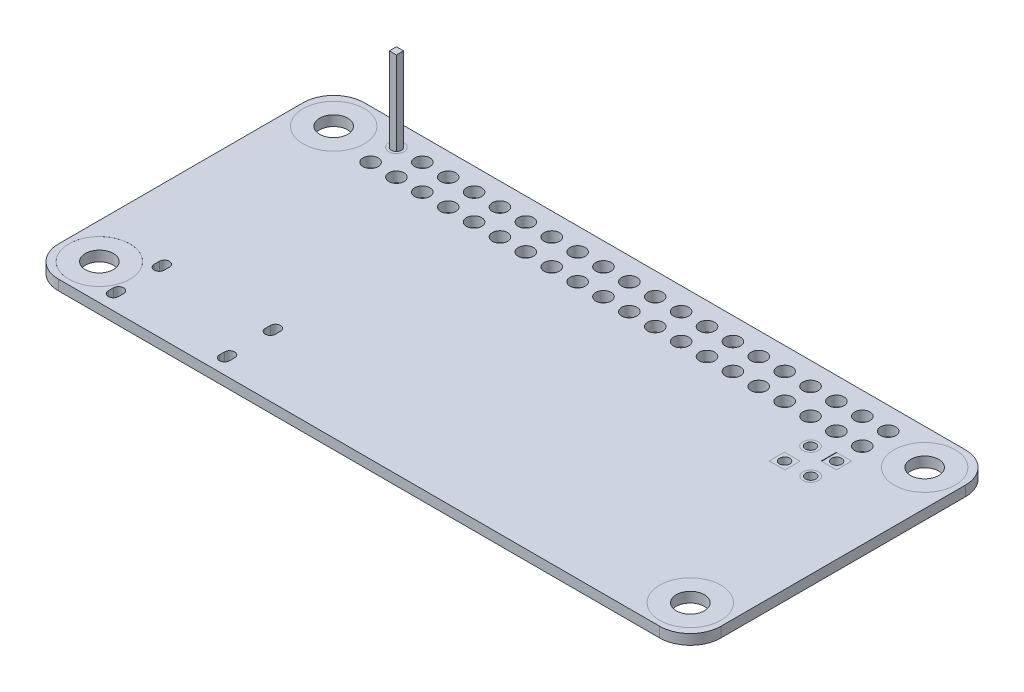
from build123d import *

# Parameters (mm, degrees)
SKETCH1_R                = 3
SKETCH1_R_2              = 0.75
SKETCH1_W                = 1.5
SKETCH1_H                = 1.5
BOSS_EXTRUDE1_DEPTH      = 1
SKETCH2_R                = 0.75
SKETCH2_R_2              = 0.5
BOSS_EXTRUDE2_DEPTH      = 1
SKETCH6_W                = 0.7
SKETCH6_H                = 0.7
BOSS_EXTRUDE5_DEPTH      = 8.2
BOSS_EXTRUDE5_DEPTH_BACK = 3
SKETCH3_R                = 0.75
SKETCH3_R_2              = 0.5
BOSS_EXTRUDE3_DEPTH      = 1
BOSS_EXTRUDE3_2_DEPTH    = 1
SKETCH3_W                = 1.541222488
SKETCH3_H                = 1.5
BOSS_EXTRUDE3_3_DEPTH    = 1
SKETCH3_W_2              = 1.458777511
BOSS_EXTRUDE3_4_DEPTH    = 1
SKETCH4_R                = 3
SKETCH4_R_2              = 1.375
BOSS_EXTRUDE4_DEPTH      = 1
CUT_EXTRUDE1_DEPTH       = 1


with BuildPart() as part:
    # Sketch1 → Boss-Extrude1 (new body)
    with BuildSketch(Plane(origin=(0, 0, 0), x_dir=(1, 0, 0), z_dir=(0, 1, 0))):
        with BuildLine():
            Line((-29.5, -15), (29.5, -15))
            ThreePointArc((29.5, -15), (31.621320344, -14.121320344), (32.5, -12))
            Line((32.5, -12), (32.5, 12))
            ThreePointArc((32.5, 12), (31.621320344, 14.121320344), (29.5, 15))
            Line((29.5, 15), (-29.5, 15))
            ThreePointArc((-29.5, 15), (-31.621320344, 14.121320344), (-32.5, 12))
            Line((-32.5, 12), (-32.5, -12))
            ThreePointArc((-32.5, -12), (-31.621320344, -14.121320344), (-29.5, -15))
        make_face()
        with Locations((-29, 11.5)):
            Circle(SKETCH1_R, mode=Mode.SUBTRACT)
        with Locations((-29, -11.5)):
            Circle(SKETCH1_R, mode=Mode.SUBTRACT)
        with Locations((29, -11.5)):
            Circle(SKETCH1_R, mode=Mode.SUBTRACT)
        with Locations((-24.13, 12.787653136)):
            Circle(SKETCH1_R_2, mode=Mode.SUBTRACT)
        with Locations((-21.59, 12.787653136)):
            Circle(SKETCH1_R_2, mode=Mode.SUBTRACT)
        with Locations((-19.05, 12.787653136)):
            Circle(SKETCH1_R_2, mode=Mode.SUBTRACT)
        with Locations((-16.51, 12.787653136)):
            Circle(SKETCH1_R_2, mode=Mode.SUBTRACT)
        with Locations((-13.97, 12.787653136)):
            Circle(SKETCH1_R_2, mode=Mode.SUBTRACT)
        with Locations((-11.43, 12.787653136)):
            Circle(SKETCH1_R_2, mode=Mode.SUBTRACT)
        with Locations((-8.89, 12.787653136)):
            Circle(SKETCH1_R_2, mode=Mode.SUBTRACT)
        with Locations((-6.35, 12.787653136)):
            Circle(SKETCH1_R_2, mode=Mode.SUBTRACT)
        with Locations((-3.81, 12.787653136)):
            Circle(SKETCH1_R_2, mode=Mode.SUBTRACT)
        with Locations((-1.27, 12.787653136)):
            Circle(SKETCH1_R_2, mode=Mode.SUBTRACT)
        with Locations((1.27, 12.787653136)):
            Circle(SKETCH1_R_2, mode=Mode.SUBTRACT)
        with Locations((3.81, 12.787653136)):
            Circle(SKETCH1_R_2, mode=Mode.SUBTRACT)
        with Locations((6.35, 12.787653136)):
            Circle(SKETCH1_R_2, mode=Mode.SUBTRACT)
        with Locations((8.89, 12.787653136)):
            Circle(SKETCH1_R_2, mode=Mode.SUBTRACT)
        with Locations((11.43, 12.787653136)):
            Circle(SKETCH1_R_2, mode=Mode.SUBTRACT)
        with Locations((13.97, 12.787653136)):
            Circle(SKETCH1_R_2, mode=Mode.SUBTRACT)
        with Locations((16.51, 12.787653136)):
            Circle(SKETCH1_R_2, mode=Mode.SUBTRACT)
        with Locations((19.05, 12.787653136)):
            Circle(SKETCH1_R_2, mode=Mode.SUBTRACT)
        with Locations((21.59, 12.787653136)):
            Circle(SKETCH1_R_2, mode=Mode.SUBTRACT)
        with Locations((24.13, 12.787653136)):
            Circle(SKETCH1_R_2, mode=Mode.SUBTRACT)
        with Locations((-21.59, 10.247653136)):
            Circle(SKETCH1_R_2, mode=Mode.SUBTRACT)
        with Locations((-19.05, 10.247653136)):
            Circle(SKETCH1_R_2, mode=Mode.SUBTRACT)
        with Locations((-16.51, 10.247653136)):
            Circle(SKETCH1_R_2, mode=Mode.SUBTRACT)
        with Locations((-13.97, 10.247653136)):
            Circle(SKETCH1_R_2, mode=Mode.SUBTRACT)
        with Locations((-11.43, 10.247653136)):
            Circle(SKETCH1_R_2, mode=Mode.SUBTRACT)
        with Locations((-8.89, 10.247653136)):
            Circle(SKETCH1_R_2, mode=Mode.SUBTRACT)
        with Locations((-6.35, 10.247653136)):
            Circle(SKETCH1_R_2, mode=Mode.SUBTRACT)
        with Locations((-3.81, 10.247653136)):
            Circle(SKETCH1_R_2, mode=Mode.SUBTRACT)
        with Locations((-1.27, 10.247653136)):
            Circle(SKETCH1_R_2, mode=Mode.SUBTRACT)
        with Locations((1.27, 10.247653136)):
            Circle(SKETCH1_R_2, mode=Mode.SUBTRACT)
        with Locations((3.81, 10.247653136)):
            Circle(SKETCH1_R_2, mode=Mode.SUBTRACT)
        with Locations((6.35, 10.247653136)):
            Circle(SKETCH1_R_2, mode=Mode.SUBTRACT)
        with Locations((8.89, 10.247653136)):
            Circle(SKETCH1_R_2, mode=Mode.SUBTRACT)
        with Locations((11.43, 10.247653136)):
            Circle(SKETCH1_R_2, mode=Mode.SUBTRACT)
        with Locations((13.97, 10.247653136)):
            Circle(SKETCH1_R_2, mode=Mode.SUBTRACT)
        with Locations((16.51, 10.247653136)):
            Circle(SKETCH1_R_2, mode=Mode.SUBTRACT)
        with Locations((19.05, 10.247653136)):
            Circle(SKETCH1_R_2, mode=Mode.SUBTRACT)
        with Locations((21.59, 10.247653136)):
            Circle(SKETCH1_R_2, mode=Mode.SUBTRACT)
        with Locations((24.13, 10.247653136)):
            Circle(SKETCH1_R_2, mode=Mode.SUBTRACT)
        with Locations((-24.13, 10.247653136)):
            Circle(SKETCH1_R_2, mode=Mode.SUBTRACT)
        with Locations((21.59002512, 7.707653136)):
            Circle(SKETCH1_R_2, mode=Mode.SUBTRACT)
        with Locations((24.150636364, 5.167736764)):
            Circle(SKETCH1_R_2, mode=Mode.SUBTRACT)
        with Locations((29, 11.5)):
            Circle(SKETCH1_R, mode=Mode.SUBTRACT)
        with Locations((24.13002512, 7.707653136)):
            Rectangle(SKETCH1_W, SKETCH1_H, mode=Mode.SUBTRACT)
        with Locations((21.610636364, 5.167736764)):
            Rectangle(SKETCH1_W, SKETCH1_H, mode=Mode.SUBTRACT)
    extrude(amount=BOSS_EXTRUDE1_DEPTH)

    # Sketch5 → Cut-Extrude1 (cut)
    with BuildSketch(Plane.XZ):
        with BuildLine():
            Line((-26.078842351, 13.039495396), (-26.078842351, 13.539495396))
            ThreePointArc((-26.078842351, 13.539495396), (-25.578842351, 14.039495396), (-25.078842351, 13.539495396))
            Line((-25.078842351, 13.539495396), (-25.078842351, 13.039495396))
            ThreePointArc((-25.078842351, 13.039495396), (-25.578842351, 12.539495396), (-26.078842351, 13.039495396))
        make_face()
        with BuildLine():
            Line((-15.178842351, 13.039495396), (-15.178842351, 13.539495396))
            ThreePointArc((-15.178842351, 13.539495396), (-14.678842351, 14.039495396), (-14.178842351, 13.539495396))
            Line((-14.178842351, 13.539495396), (-14.178842351, 13.039495396))
            ThreePointArc((-14.178842351, 13.039495396), (-14.678842351, 12.539495396), (-15.178842351, 13.039495396))
        make_face()
        with BuildLine():
            Line((-15.178842351, 8.539495396), (-15.178842351, 9.039495396))
            ThreePointArc((-15.178842351, 9.039495396), (-14.678842351, 9.539495396), (-14.178842351, 9.039495396))
            Line((-14.178842351, 9.039495396), (-14.178842351, 8.539495396))
            ThreePointArc((-14.178842351, 8.539495396), (-14.678842351, 8.039495396), (-15.178842351, 8.539495396))
        make_face()
        with BuildLine():
            Line((-26.078842351, 8.539495396), (-26.078842351, 9.039495396))
            ThreePointArc((-26.078842351, 9.039495396), (-25.578842351, 9.539495396), (-25.078842351, 9.039495396))
            Line((-25.078842351, 9.039495396), (-25.078842351, 8.539495396))
            ThreePointArc((-25.078842351, 8.539495396), (-25.578842351, 8.039495396), (-26.078842351, 8.539495396))
        make_face()
    extrude(amount=-CUT_EXTRUDE1_DEPTH, mode=Mode.SUBTRACT)


with BuildPart() as body_2:
    # Sketch2 → Boss-Extrude2 (new body)
    with BuildSketch(Plane(origin=(0, 0, 0), x_dir=(1, 0, 0), z_dir=(0, 1, 0))):
        with Locations((-24.13, 12.787653136)):
            Circle(SKETCH2_R)
        with Locations((-24.13, 12.787653136)):
            Circle(SKETCH2_R_2, mode=Mode.SUBTRACT)
    extrude(amount=BOSS_EXTRUDE2_DEPTH)


with BuildPart() as body_3:
    # Sketch6 → Boss-Extrude5 (new body, two sides)
    with BuildSketch(Plane(origin=(0, 1, 0), x_dir=(1, 0, 0), z_dir=(0, 1, 0))) as boss_extrude5_sk:
        with Locations((-24.13, 12.787653136)):
            Rectangle(SKETCH6_W, SKETCH6_H)
    extrude(amount=BOSS_EXTRUDE5_DEPTH)
    extrude(boss_extrude5_sk.sketch, amount=-BOSS_EXTRUDE5_DEPTH_BACK)


with BuildPart() as body_4:
    # Sketch3 → Boss-Extrude3 (new body)
    with BuildSketch(Plane(origin=(0, 0, 0), x_dir=(1, 0, 0), z_dir=(0, 1, 0))):
        with Locations((21.59002512, 7.707653136)):
            Circle(SKETCH3_R)
        with Locations((21.59002512, 7.707653136)):
            Circle(SKETCH3_R_2, mode=Mode.SUBTRACT)
    extrude(amount=BOSS_EXTRUDE3_DEPTH)


with BuildPart() as body_5:
    # Sketch3 → Boss-Extrude3 2 (new body)
    with BuildSketch(Plane(origin=(0, 0, 0), x_dir=(1, 0, 0), z_dir=(0, 1, 0))):
        with Locations((24.150636364, 5.167736764)):
            Circle(SKETCH3_R)
        with Locations((24.150636364, 5.167736764)):
            Circle(SKETCH3_R_2, mode=Mode.SUBTRACT)
    extrude(amount=BOSS_EXTRUDE3_2_DEPTH)


with BuildPart() as body_6:
    # Sketch3 → Boss-Extrude3 3 (new body)
    with BuildSketch(Plane(origin=(0, 0, 0), x_dir=(1, 0, 0), z_dir=(0, 1, 0))):
        with Locations((21.59002512, 5.167736764)):
            Rectangle(SKETCH3_W, SKETCH3_H)
        with Locations((21.59002512, 5.167736764)):
            Circle(SKETCH3_R_2, mode=Mode.SUBTRACT)
    extrude(amount=BOSS_EXTRUDE3_3_DEPTH)


with BuildPart() as body_7:
    # Sketch3 → Boss-Extrude3 4 (new body)
    with BuildSketch(Plane(origin=(0, 0, 0), x_dir=(1, 0, 0), z_dir=(0, 1, 0))):
        with Locations((24.150636365, 7.707653136)):
            Rectangle(SKETCH3_W_2, SKETCH3_H)
        with Locations((24.150636364, 7.707653136)):
            Circle(SKETCH3_R_2, mode=Mode.SUBTRACT)
    extrude(amount=BOSS_EXTRUDE3_4_DEPTH)


with BuildPart() as body_8:
    # Sketch4 → Boss-Extrude4 (new body)
    with BuildSketch(Plane(origin=(0, 0, 0), x_dir=(1, 0, 0), z_dir=(0, 1, 0))):
        with Locations((-29, 11.5)):
            Circle(SKETCH4_R)
        with Locations((-29, 11.5)):
            Circle(SKETCH4_R_2, mode=Mode.SUBTRACT)
    extrude(amount=BOSS_EXTRUDE4_DEPTH)


with BuildPart() as body_9:
    # Mirror1: mirrored copy
    add(body_8.part.mirror(Plane(origin=(0, 0, 0), x_dir=(0, 0, 1), z_dir=(1, 0, 0))))


with BuildPart() as body_10:
    # Mirror2: mirrored copy
    add(body_8.part.mirror(Plane.XY))


with BuildPart() as body_11:
    # Mirror2 2: mirrored copy
    add(body_9.part.mirror(Plane.XY))


solid = Compound([part.part, body_2.part, body_3.part, body_4.part, body_5.part, body_6.part, body_7.part, body_8.part, body_9.part, body_10.part, body_11.part])
